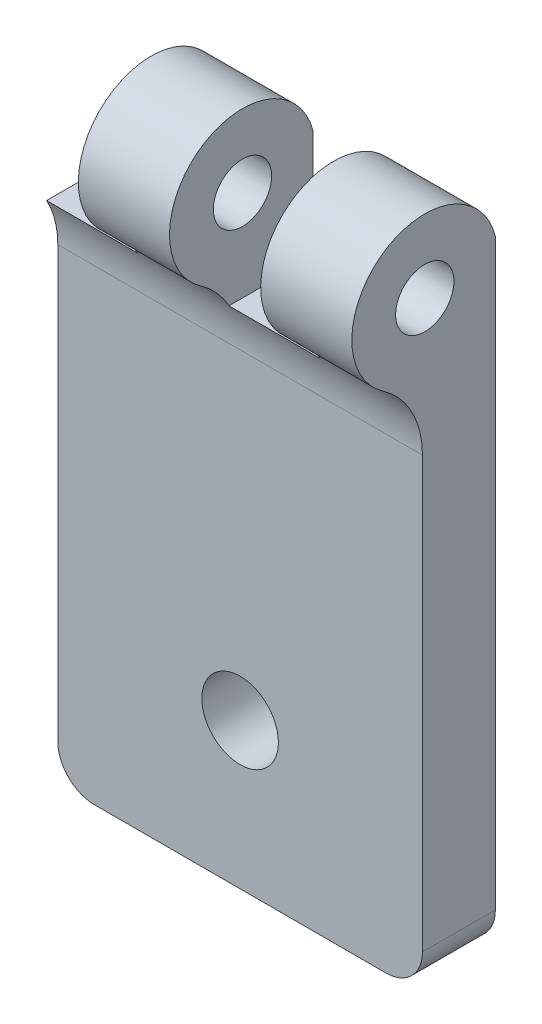
from build123d import *

# Parameters (mm, degrees)
SKETCH1_W           = 20
SKETCH1_H           = 34
BOSS_EXTRUDE1_DEPTH = 4
BOSS_EXTRUDE2_DEPTH = 20
FILLET1_R           = 5
SKETCH3_R           = 1.6
CUT_EXTRUDE1_DEPTH  = 21
SKETCH4_R           = 2.1
CUT_EXTRUDE2_DEPTH  = 5
FILLET2_R           = 2
SKETCH5_W           = 5
SKETCH5_H           = 12
CUT_EXTRUDE3_DEPTH  = 8.872457626


with BuildPart() as part:
    # Sketch1 → Boss-Extrude1 (new body)
    with BuildSketch(Plane.XY):
        with Locations((-10, 17)):
            Rectangle(SKETCH1_W, SKETCH1_H)
    extrude(amount=BOSS_EXTRUDE1_DEPTH)

    # Sketch2 → Boss-Extrude2 (add)
    with BuildSketch(Plane(origin=(0, 0, 0), x_dir=(0, 0, -1), z_dir=(1, 0, 0))):
        with BuildLine():
            Line((-4, 29), (-4, 34))
            Line((-4, 34), (0, 34))
            ThreePointArc((0, 34), (-6.995932864, 35.496746291), (-4, 29))
        make_face()
    extrude(amount=-BOSS_EXTRUDE2_DEPTH)

    # Fillet1
    fillet1_edges = [part.edges().sort_by_distance(p)[0] for p in [
        (-10, 29, 4),
    ]]
    fillet(fillet1_edges, radius=FILLET1_R)

    # Sketch3 → Cut-Extrude1 (cut, through all)
    with BuildSketch(Plane(origin=(0, 0, 0), x_dir=(0, 0, -1), z_dir=(1, 0, 0))):
        with Locations((-3.872457626, 32.997966101)):
            Circle(SKETCH3_R)
    extrude(amount=-CUT_EXTRUDE1_DEPTH, mode=Mode.SUBTRACT)

    # Sketch4 → Cut-Extrude2 (cut, through all)
    with BuildSketch(Plane.XY.offset(4)):
        with Locations((-10, 8)):
            Circle(SKETCH4_R)
    extrude(amount=-CUT_EXTRUDE2_DEPTH, mode=Mode.SUBTRACT)

    # Fillet2
    fillet2_edges = [part.edges().sort_by_distance(p)[0] for p in [
        (0, 0, 2),
        (-20, 0, 2),
    ]]
    fillet(fillet2_edges, radius=FILLET2_R)

    # Sketch5 → Cut-Extrude3 (cut, through all)
    with BuildSketch(Plane(origin=(0, 0, 0), x_dir=(-1, 0, 0), z_dir=(0, 0, -1))):
        with Locations((7.5, 34)):
            Rectangle(SKETCH5_W, SKETCH5_H)
        with Locations((17.5, 34)):
            Rectangle(SKETCH5_W, SKETCH5_H)
    extrude(amount=-CUT_EXTRUDE3_DEPTH, mode=Mode.SUBTRACT)


solid = part.part
